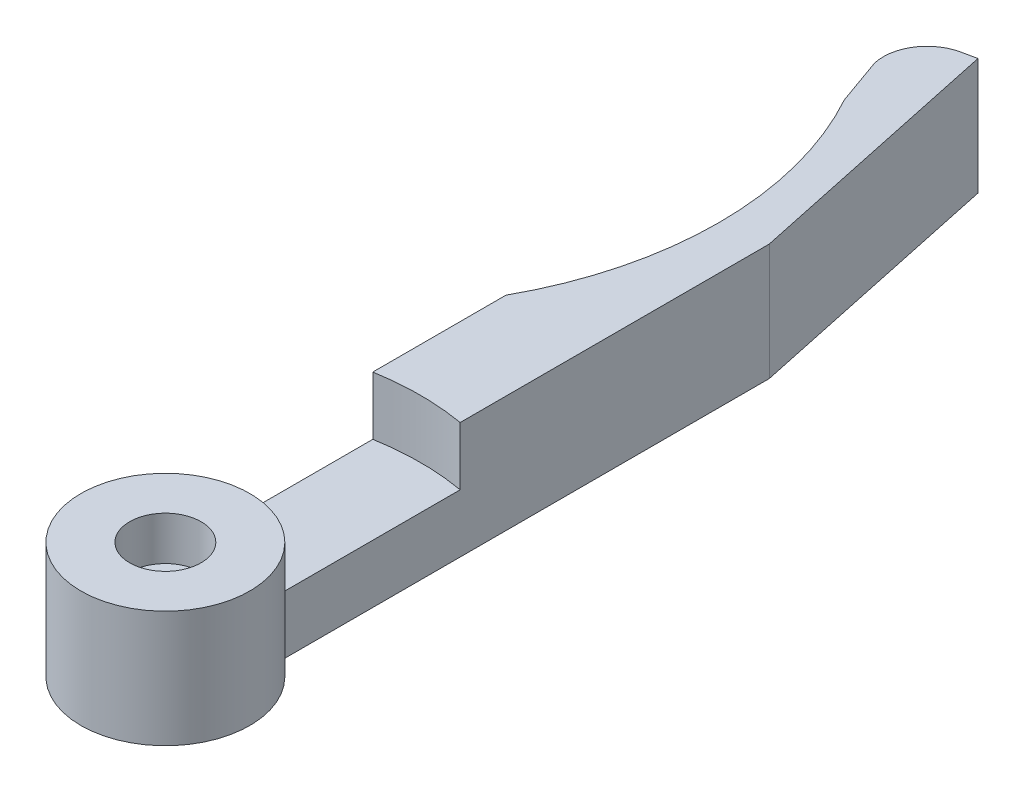
from build123d import *

# Parameters (mm, degrees)
BOSS_EXTRU_1_DEPTH      = 8
ESQUISSE2_R             = 2.45
ENL_V_MAT_EXTRU_1_DEPTH = 3
ENL_V_MAT_EXTRU_2_REACH = 7
ESQUISSE3_R             = 1.25
ESQUISSE4_R             = 3
ENL_V_MAT_EXTRU_3_DEPTH = 2
ENL_V_MAT_EXTRU_4_DEPTH = 4


with BuildPart() as part:
    # Esquisse1 → Boss.-Extru.1 (new body)
    with BuildSketch(Plane(origin=(0, 0, 0), x_dir=(1, 0, 0), z_dir=(0, 1, 0))):
        with BuildLine():
            Line((-3, 26.381049961), (-3, 4.963869458))
            ThreePointArc((-3, 4.963869458), (0, -5.8), (3, 4.963869458))
            Line((3, 4.963869458), (3, 38.463869458))
            Line((3, 38.463869458), (-0.867157449, 56.657414832))
            Line((-0.867157449, 56.657414832), (-1.84530505, 56.449503141))
            ThreePointArc((-1.84530505, 56.449503141), (-3.756758837, 55.119060789), (-4.140414176, 52.821988519))
            Line((-4.140414176, 52.821988519), (-3, 49.618950039))
            ThreePointArc((-3, 49.618950039), (0, 38), (-3, 26.381049961))
        make_face()
    extrude(amount=BOSS_EXTRU_1_DEPTH)

    # Esquisse2 → Enlèv. mat.-Extru.1 (cut)
    with BuildSketch(Plane(origin=(0, 8, 0), x_dir=(1, 0, 0), z_dir=(0, 1, 0))):
        Circle(ESQUISSE2_R)
    extrude(amount=-ENL_V_MAT_EXTRU_1_DEPTH, mode=Mode.SUBTRACT)

    # Esquisse3 → Enlèv. mat.-Extru.2 (cut, up to next)
    with BuildSketch(Plane(origin=(0, 5, 0), x_dir=(1, 0, 0), z_dir=(0, 1, 0)), mode=Mode.PRIVATE) as enl_v_mat_extru_2_sk1:
        Circle(ESQUISSE3_R)
    enl_v_mat_extru_2_tool1 = extrude(enl_v_mat_extru_2_sk1.sketch, amount=-ENL_V_MAT_EXTRU_2_REACH, mode=Mode.PRIVATE) & part.part
    add(enl_v_mat_extru_2_tool1.solids().sort_by_distance((0, 5, 0))[0], mode=Mode.SUBTRACT)

    # Esquisse4 → Enlèv. mat.-Extru.3 (cut)
    with BuildSketch(Plane.XZ):
        Circle(ESQUISSE4_R)
    extrude(amount=-ENL_V_MAT_EXTRU_3_DEPTH, mode=Mode.SUBTRACT)

    # Esquisse5 → Enlèv. mat.-Extru.4 (cut)
    with BuildSketch(Plane(origin=(0, 8, 0), x_dir=(1, 0, 0), z_dir=(0, 1, 0))):
        with BuildLine():
            Line((-3, 4.963869458), (-3, 17.24093965))
            ThreePointArc((-3, 17.24093965), (0, 17.5), (3, 17.24093965))
            Line((3, 17.24093965), (3, 4.963869458))
            ThreePointArc((3, 4.963869458), (0, 5.8), (-3, 4.963869458))
        make_face()
    extrude(amount=-ENL_V_MAT_EXTRU_4_DEPTH, mode=Mode.SUBTRACT)


solid = part.part
